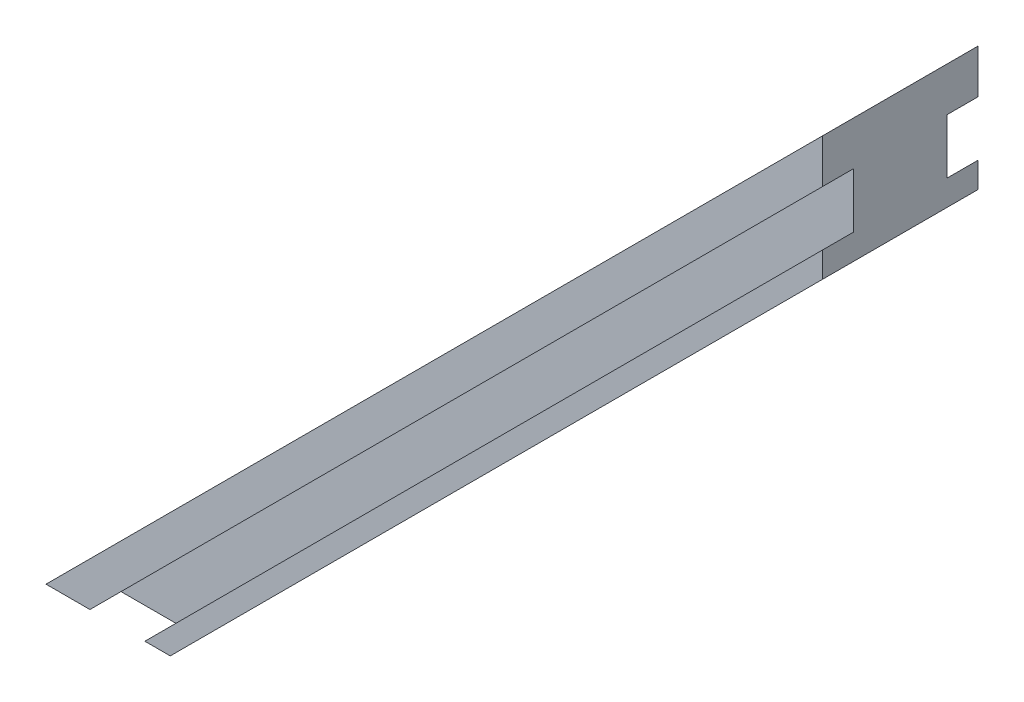
from build123d import *

# Parameters (mm, degrees)
MAIN_DEPTH         = 5
WINDOWSLOT1_DEPTH  = 2
SKETCH6_R          = 1.25
CUT_EXTRUDE2_DEPTH = 5
LPATTERN1_COUNT    = 5
LPATTERN1_PITCH    = 10
SKETCH7_R          = 3.5
CUT_EXTRUDE4_DEPTH = 1.5


with BuildPart() as part:
    # Sketch1 → Main (new body, symmetric)
    with BuildSketch(Plane.XY):
        Polygon((-25, -25), (25, 25), (25, 17), (-17, -25), align=None)
    extrude(amount=MAIN_DEPTH, both=True)

    # Sketch4 → WindowSlot1 (cut)
    with BuildSketch(Plane.XY.offset(5)):
        Polygon((25, 22.171572875), (-22.171572875, -25), (-18.636038969, -25), (25, 18.636038969), align=None)
    windowslot1 = extrude(amount=-WINDOWSLOT1_DEPTH, mode=Mode.SUBTRACT)

    # Mirror1: WindowSlot1 across plane
    add(windowslot1.mirror(Plane.XY), mode=Mode.SUBTRACT)

    # Sketch6 → Cut-Extrude2 (cut)
    with BuildSketch(Plane(origin=(4, -4, 0), x_dir=(0, 0, 1), z_dir=(-0.707106781, 0.707106781, 0))):
        with Locations((0, 20)):
            Circle(SKETCH6_R)
    cut_extrude2 = extrude(amount=CUT_EXTRUDE2_DEPTH, mode=Mode.SUBTRACT)

    # LPattern1: Cut-Extrude2 ×5
    with Locations(*[Vector(-0.707106781, -0.707106781, 0) * (i * LPATTERN1_PITCH) for i in range(1, LPATTERN1_COUNT)]):
        add(cut_extrude2, mode=Mode.SUBTRACT)

    # Sketch7 → Cut-Extrude4 (cut)
    with BuildSketch(Plane(origin=(0, 0, 0), x_dir=(0, 0, 1), z_dir=(-0.707106781, 0.707106781, 0))):
        with Locations((0, 20)):
            Circle(SKETCH7_R)
        with Locations((0, -20)):
            Circle(SKETCH7_R)
    extrude(amount=-CUT_EXTRUDE4_DEPTH, mode=Mode.SUBTRACT)


solid = part.part
